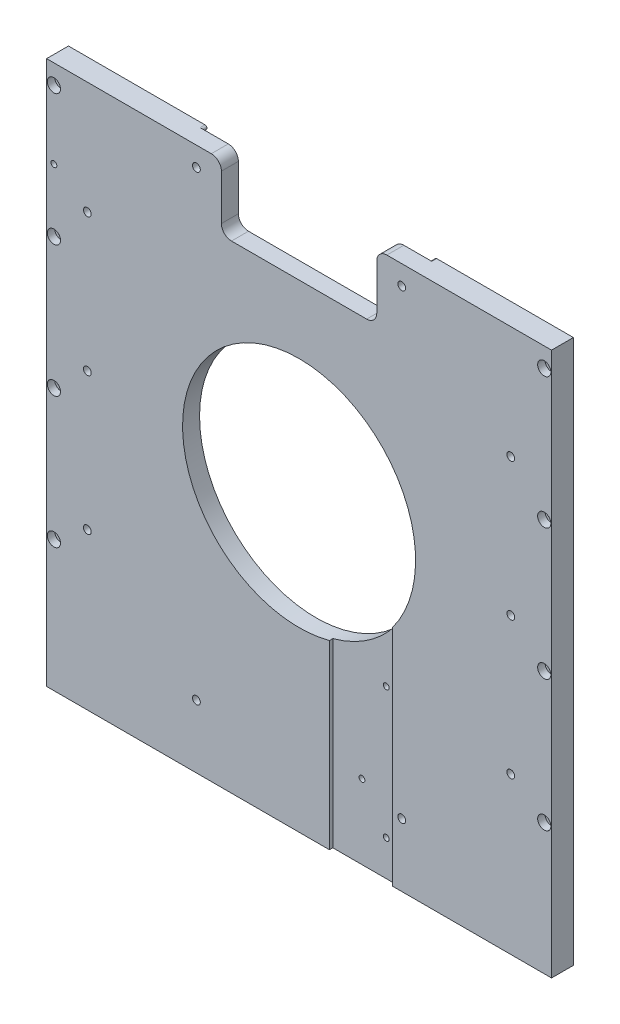
from build123d import *

# Parameters (mm, degrees)
SKETCH1_W                                       = 330.2
SKETCH1_H                                       = 355.6
SKETCH1_R                                       = 76.2
BOSS_EXTRUDE1_DEPTH                             = 14.2875
CUT_EXTRUDE1_DEPTH                              = 2.2098
SKETCH2_R                                       = 76.2
CUT_EXTRUDE2_DEPTH                              = 3.175
SKETCH2_3_W                                     = 101.6
SKETCH2_3_H                                     = 42.8625
CUT_EXTRUDE3_DEPTH                              = 15.2875
FILLET1_R                                       = 6.604
FILLET2_R                                       = 6.35
FILLET3_R                                       = 1.27
F_1_4_20_TAPPED_HOLE1_D                         = 5.1054
F_10_24_TAPPED_HOLE1_D                          = 3.7973
CBORE_FOR_10_SOCKET_HEAD_CAP_SCREW2_D           = 5.1054
CBORE_FOR_10_SOCKET_HEAD_CAP_SCREW2_CBORE_D     = 8.636
CBORE_FOR_10_SOCKET_HEAD_CAP_SCREW2_CBORE_DEPTH = 4.826
F_10_24_TAPPED_HOLE2_D                          = 3.7973
F_10_24_TAPPED_HOLE2_DEPTH                      = 14.9606
F_10_24_TAPPED_HOLE2_TIP                        = 1.140824014
F_6_CLEARANCE_HOLE1_D                           = 3.7973


with BuildPart() as part:
    # Sketch1 → Boss-Extrude1 (new body)
    with BuildSketch(Plane.XY):
        with Locations((0, -14.2875)):
            Rectangle(SKETCH1_W, SKETCH1_H)
        Circle(SKETCH1_R, mode=Mode.SUBTRACT)
    extrude(amount=-BOSS_EXTRUDE1_DEPTH)

    # Sketch1_3 → Cut-Extrude1 (cut)
    with BuildSketch(Plane.XY):
        with BuildLine():
            Line((19.8628, -73.565679336), (19.8628, -192.0875))
            Line((19.8628, -192.0875), (61.1378, -192.0875))
            Line((61.1378, -192.0875), (61.1378, -45.481967978))
            ThreePointArc((61.1378, -45.481967978), (42.865464082, -62.999936421), (19.8628, -73.565679336))
        make_face()
    extrude(amount=-CUT_EXTRUDE1_DEPTH, mode=Mode.SUBTRACT)

    # Sketch2 → Cut-Extrude2 (cut)
    with BuildSketch(Plane(origin=(0, 0, -14.2875), x_dir=(-1, 0, 0), z_dir=(0, 0, -1))):
        with BuildLine():
            Line((50.8, 170.388379885), (50.8, 163.5125))
            Line((50.8, 163.5125), (-50.8, 163.5125))
            Line((-50.8, 163.5125), (-50.8, 170.388379885))
            ThreePointArc((-50.8, 170.388379885), (-111.466407665, 138.521045196), (-155.575, 86.077054869))
            Line((-155.575, 86.077054869), (-155.575, -86.077054869))
            ThreePointArc((-155.575, -86.077054869), (0, -177.8), (155.575, -86.077054869))
            Line((155.575, -86.077054869), (155.575, 86.077054869))
            ThreePointArc((155.575, 86.077054869), (111.466407665, 138.521045196), (50.8, 170.388379885))
        make_face()
        with Locations(Location((0, 0, 0), (0, 0, 216.646499469))):  # turned: the seam where the file's is
            Circle(SKETCH2_R, mode=Mode.SUBTRACT)
    extrude(amount=-CUT_EXTRUDE2_DEPTH, mode=Mode.SUBTRACT)

    # Sketch2_3 → Cut-Extrude3 (cut, through all)
    with BuildSketch(Plane(origin=(0, 0, -14.2875), x_dir=(-1, 0, 0), z_dir=(0, 0, -1))):
        with Locations((0, 142.08125)):
            Rectangle(SKETCH2_3_W, SKETCH2_3_H)
    extrude(amount=-CUT_EXTRUDE3_DEPTH, mode=Mode.SUBTRACT)

    # Fillet1
    fillet1_edges = [part.edges().sort_by_distance(p)[0] for p in [
        (-50.8, 163.5125, -5.55625),
        (50.8, 120.65, -5.55625),
        (-50.8, 120.65, -5.55625),
        (50.8, 163.5125, -5.55625),
    ]]
    fillet(fillet1_edges, radius=FILLET1_R)

    # Fillet2
    fillet2_edges = [part.edges().sort_by_distance(p)[0] for p in [
        (-155.575, 86.077054869, -12.7),
        (-155.575, -86.077054869, -12.7),
        (155.575, -86.077054869, -12.7),
        (155.575, 86.077054869, -12.7),
    ]]
    fillet(fillet2_edges, radius=FILLET2_R)

    # Fillet3
    fillet3_edges = [part.edges().sort_by_distance(p)[0] for p in [
        (69.831957897, 163.5125, -12.7),
        (-69.831957897, 163.5125, -12.7),
    ]]
    fillet(fillet3_edges, radius=FILLET3_R)

    # 1_4-20 Tapped Hole1 (through all)
    with Locations(Plane(origin=(0, 0, -11.1125), x_dir=(-1, 0, 0), z_dir=(0, 0, -1))):
        with Locations((-67.152219772, 150.826355057), (-138.464510768, 89.919904681), (-138.464510768, 0), (-138.464510768, -89.919904681), (-67.152219772, -150.826355057), (67.152219772, -150.826355057), (138.464510768, -89.919904681), (138.464510768, 0), (138.464510768, 89.919904681), (67.152219772, 150.826355057)):
            Hole(F_1_4_20_TAPPED_HOLE1_D / 2)

    # 10-24 Tapped Hole1 (through all)
    with Locations(Plane.XY.offset(-2.2098)):
        with Locations((54.7878, -83.1723), (54.7878, -168.8973), (38.9128, -143.4973)):
            Hole(F_10_24_TAPPED_HOLE1_D / 2)

    # CBORE for _10 Socket Head Cap Screw2 (through all)
    with Locations(Plane.XY):
        with Locations((-160.3375, -106.3625), (160.3375, -106.3625), (160.3375, -20.6375), (160.3375, 65.0875), (160.3375, 150.8125), (-160.3375, -20.6375), (-160.3375, 65.0875), (-160.3375, 150.8125)):
            CounterBoreHole(CBORE_FOR_10_SOCKET_HEAD_CAP_SCREW2_D / 2, CBORE_FOR_10_SOCKET_HEAD_CAP_SCREW2_CBORE_D / 2, CBORE_FOR_10_SOCKET_HEAD_CAP_SCREW2_CBORE_DEPTH)

    # 10-24 Tapped Hole2
    with Locations(Plane(origin=(0, -192.0875, 0), x_dir=(-1, 0, 0), z_dir=(0, -1, 0))):
        with Locations((76.2, 7.1501), (-76.2, 7.1501)):
            Hole(F_10_24_TAPPED_HOLE2_D / 2, depth=F_10_24_TAPPED_HOLE2_DEPTH)
            with Locations((0, 0, -(F_10_24_TAPPED_HOLE2_DEPTH + F_10_24_TAPPED_HOLE2_TIP / 2))):  # 118° drill point
                Cone(0, F_10_24_TAPPED_HOLE2_D / 2, F_10_24_TAPPED_HOLE2_TIP, mode=Mode.SUBTRACT)

    # 6 Clearance Hole1 (through all)
    with Locations(Plane.XY):
        with Locations((-160.3375, 106.2015)):
            Hole(F_6_CLEARANCE_HOLE1_D / 2)


solid = part.part
